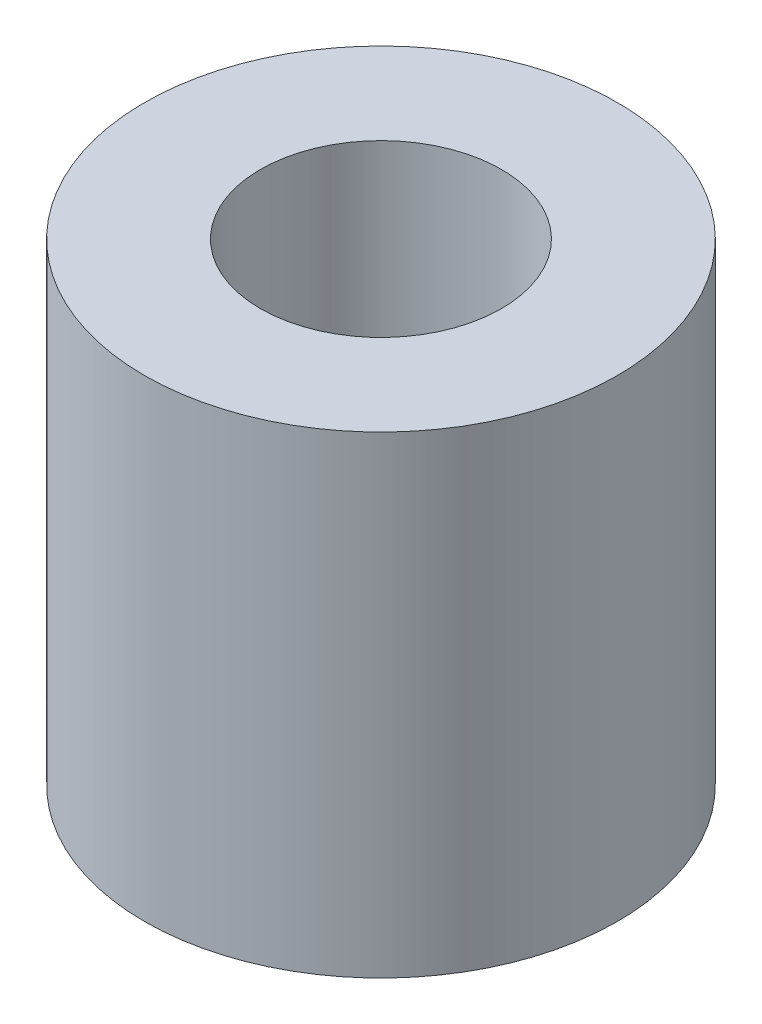
from build123d import *

# Parameters (mm, degrees)
SKIZZE1_R                 = 10
ZAPFEN_DEPTH              = 20
M12_GEWINDEBOHRUNG1_D     = 10.2
M12_GEWINDEBOHRUNG1_DEPTH = 16
M12_GEWINDEBOHRUNG1_TIP   = 3.064389157


with BuildPart() as part:
    # Skizze1 → Zapfen (new body)
    with BuildSketch(Plane(origin=(0, 0, 0), x_dir=(1, 0, 0), z_dir=(0, 1, 0))):
        with Locations(Location((0, 0, 0), (0, 0, 270))):  # turned: the seam where the file's is
            Circle(SKIZZE1_R)
    extrude(amount=ZAPFEN_DEPTH)

    # M12 Gewindebohrung1
    with Locations(Plane(origin=(0, 20, 0), x_dir=(1, 0, 0), z_dir=(0, 1, 0))):
        with Locations((0, 0)):
            Hole(M12_GEWINDEBOHRUNG1_D / 2, depth=M12_GEWINDEBOHRUNG1_DEPTH)
            with Locations((0, 0, -(M12_GEWINDEBOHRUNG1_DEPTH + M12_GEWINDEBOHRUNG1_TIP / 2))):  # 118° drill point
                Cone(0, M12_GEWINDEBOHRUNG1_D / 2, M12_GEWINDEBOHRUNG1_TIP, mode=Mode.SUBTRACT)


solid = part.part
